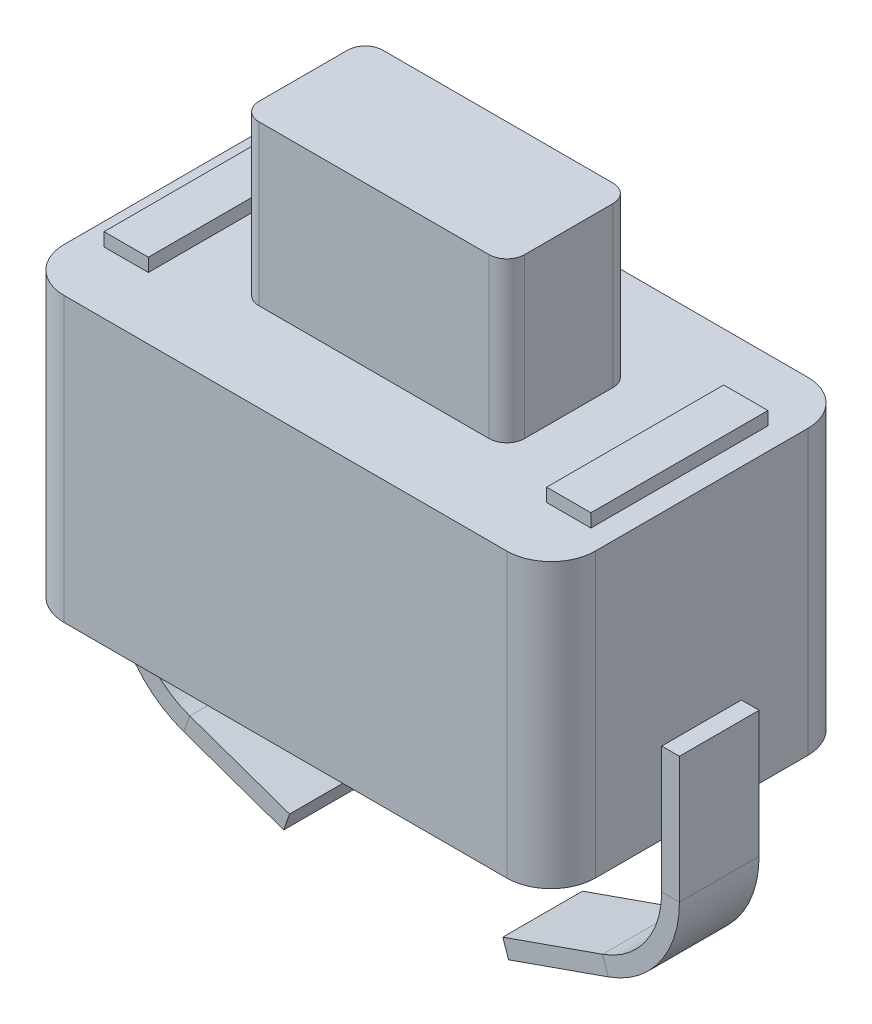
from build123d import *

# Parameters (mm, degrees)
SKETCH1_W           = 6
SKETCH1_H           = 3.4
BOSS_EXTRUDE1_DEPTH = 3.2
SKETCH2_W           = 3
SKETCH2_H           = 1.4
BOSS_EXTRUDE2_DEPTH = 1.8
SKETCH2_3_W         = 0.5
SKETCH2_3_H         = 2
BOSS_EXTRUDE3_DEPTH = 0.15
FILLET1_R           = 0.2
FILLET3_R           = 0.5
SKETCH3_W           = 0.2
SKETCH3_H           = 0.9


with BuildPart() as part:
    # Sketch1 → Boss-Extrude1 (new body)
    with BuildSketch(Plane(origin=(0, 0, 0), x_dir=(1, 0, 0), z_dir=(0, 1, 0))):
        Rectangle(SKETCH1_W, SKETCH1_H)
    extrude(amount=BOSS_EXTRUDE1_DEPTH)

    # Sketch2 → Boss-Extrude2 (add)
    with BuildSketch(Plane(origin=(0, 3.2, 0), x_dir=(1, 0, 0), z_dir=(0, 1, 0))):
        Rectangle(SKETCH2_W, SKETCH2_H)
    extrude(amount=BOSS_EXTRUDE2_DEPTH)

    # Sketch2_3 → Boss-Extrude3 (add)
    with BuildSketch(Plane(origin=(0, 3.2, 0), x_dir=(1, 0, 0), z_dir=(0, 1, 0))):
        with Locations((-2.5, 0)):
            Rectangle(SKETCH2_3_W, SKETCH2_3_H)
        with Locations((2.5, 0)):
            Rectangle(SKETCH2_3_W, SKETCH2_3_H)
    extrude(amount=BOSS_EXTRUDE3_DEPTH)

    # Fillet1
    fillet1_edges = [part.edges().sort_by_distance(p)[0] for p in [
        (-1.5, 4.1, -0.7),
        (1.5, 4.1, -0.7),
        (1.5, 4.1, 0.7),
        (-1.5, 4.1, 0.7),
    ]]
    fillet(fillet1_edges, radius=FILLET1_R)

    # Fillet3
    fillet3_edges = [part.edges().sort_by_distance(p)[0] for p in [
        (3, 1.6, 1.7),
        (3, 1.6, -1.7),
        (-3, 1.6, -1.7),
        (-3, 1.6, 1.7),
    ]]
    fillet(fillet3_edges, radius=FILLET3_R)

    # Sweep1: sweep along a path in Sketch4
    with BuildLine(Plane.XY) as sweep1_path:
        Line((-1.204114161, -1.850245601), (-2.331506907, -1.454106562))
        ThreePointArc((-2.331506907, -1.454106562), (-2.815937163, -1.088794364), (-3, -0.51065377))
        Line((-3, -0.51065377), (-3, 0))
        Line((-3, 0), (-3, 0.917319166))
    # Sketch3 → Sweep1 (sweep)
    with BuildSketch(Plane.XZ):
        with Locations((-3.1, 0)):
            Rectangle(SKETCH3_W, SKETCH3_H)
    sweep1 = sweep(path=sweep1_path.line)

    # Mirror1: Sweep1 across plane
    add(sweep1.mirror(Plane(origin=(0, 0, 0), x_dir=(0, 0, 1), z_dir=(1, 0, 0))))


solid = part.part
